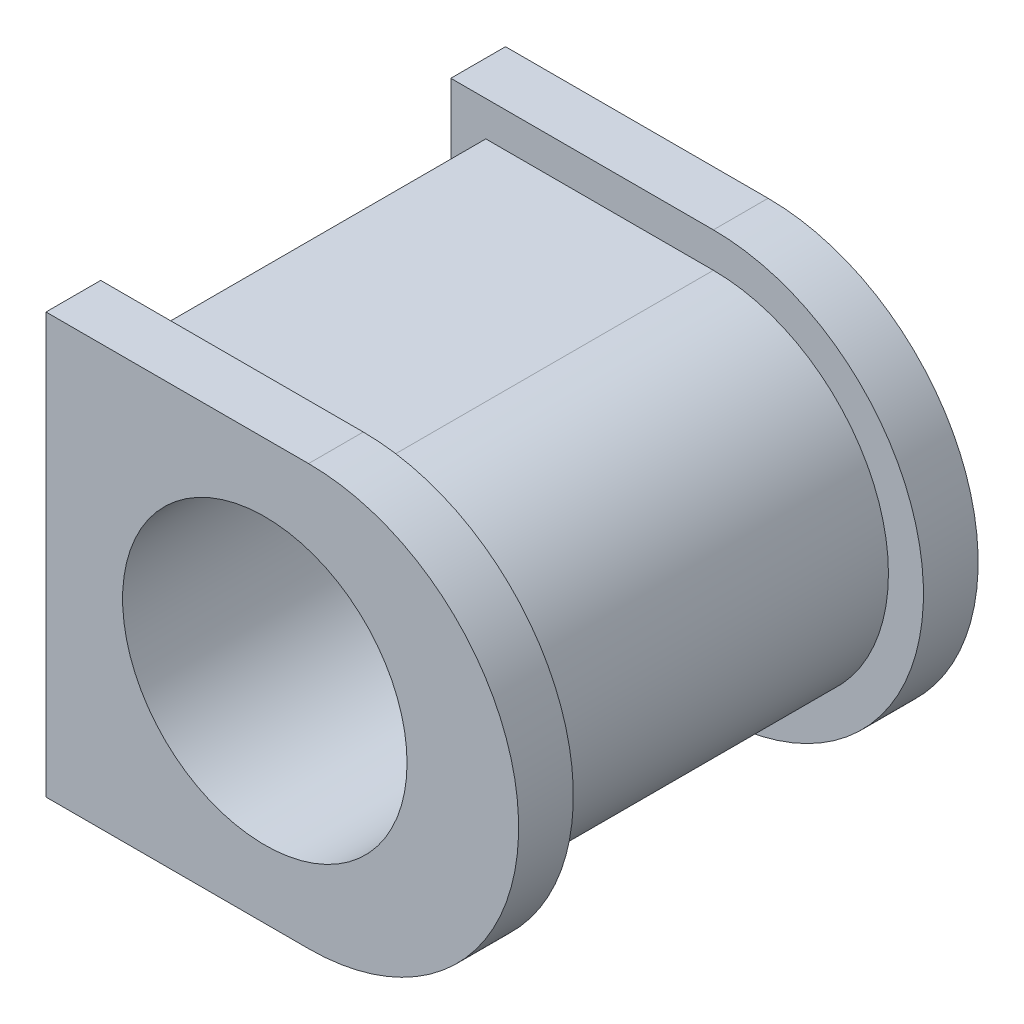
from build123d import *

# Parameters (mm, degrees)
BOSS_EXTRUDE1_DEPTH = 12.5
BOSS_EXTRUDE2_DEPTH = 80
SKETCH3_R           = 32.5
CUT_EXTRUDE1_DEPTH  = 120


with BuildPart() as part:
    # Sketch1 → Boss-Extrude1 (new body)
    with BuildSketch(Plane.XY):
        with BuildLine():
            Line((0, 48), (-60, 48))
            Line((-60, 48), (-60, -48))
            Line((-60, -48), (0, -48))
            ThreePointArc((0, -48), (48, 0), (0, 48))
        make_face()
    extrude(amount=BOSS_EXTRUDE1_DEPTH)

    # Sketch2 → Boss-Extrude2 (add)
    with BuildSketch(Plane.XY.offset(12.5)):
        with BuildLine():
            Line((0, 40), (-52, 40))
            Line((-52, 40), (-52, -40))
            Line((-52, -40), (0, -40))
            ThreePointArc((0, -40), (40, 0), (0, 40))
        make_face()
    extrude(amount=BOSS_EXTRUDE2_DEPTH)

    # Mirror1: part across plane


with BuildPart() as part_1:
    add(part.part)
    add(part.part.mirror(Plane.XY.offset(52.5)))

    # Sketch3 → Cut-Extrude1 (cut)
    with BuildSketch(Plane.XY.offset(105)):
        with Locations((-10, 0)):
            Circle(SKETCH3_R)
    extrude(amount=-CUT_EXTRUDE1_DEPTH, mode=Mode.SUBTRACT)


solid = part_1.part
